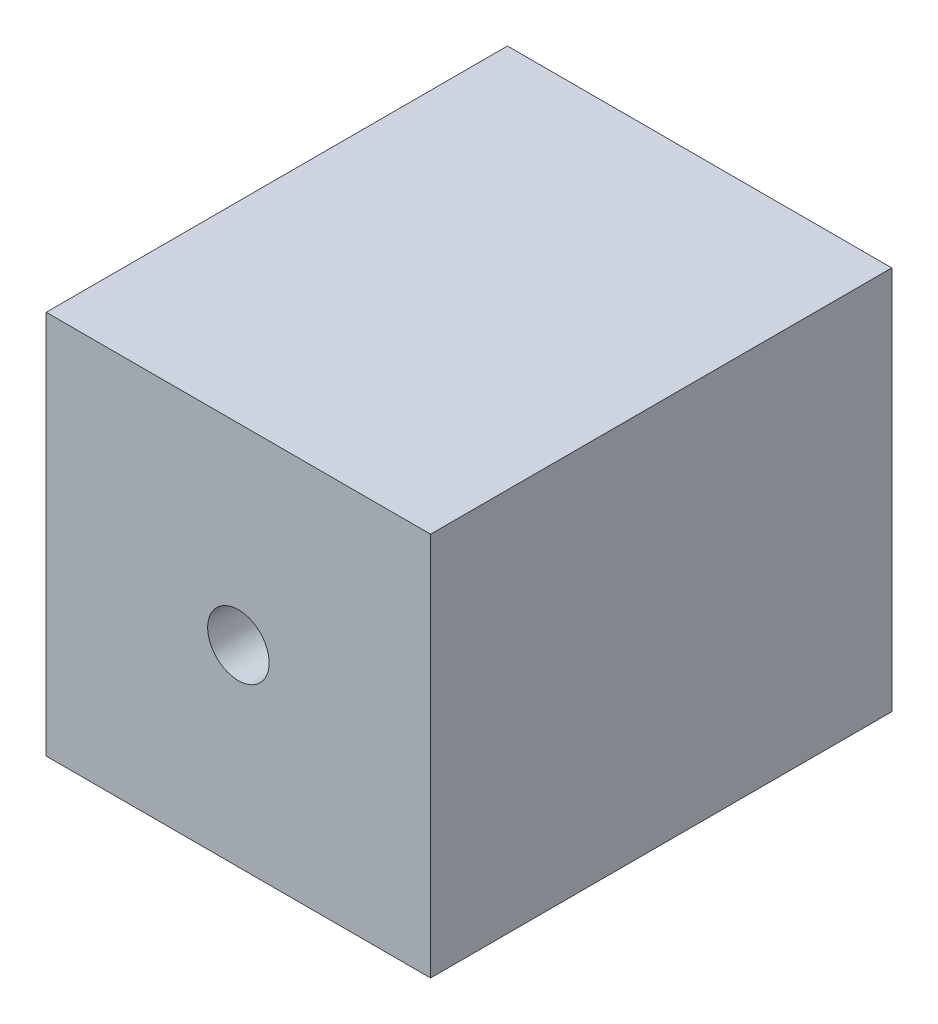
from build123d import *

# Parameters (mm, degrees)
SKETCH1_W                  = 10
SKETCH1_H                  = 10
BOSS_EXTRUDE1_DEPTH        = 12
F_10_32_TAPPED_HOLE1_D     = 4.0386
F_10_32_TAPPED_HOLE1_DEPTH = 5
F_10_32_TAPPED_HOLE1_TIP   = 1.213317848
M2X0_4_TAPPED_HOLE1_D      = 1.6
M2X0_4_TAPPED_HOLE1_DEPTH  = 7
M2X0_4_TAPPED_HOLE1_TIP    = 0.480688495


with BuildPart() as part:
    # Sketch1 → Boss-Extrude1 (new body)
    with BuildSketch(Plane.XY):
        Rectangle(SKETCH1_W, SKETCH1_H)
    extrude(amount=BOSS_EXTRUDE1_DEPTH)

    # #10-32 Tapped Hole1
    with Locations(Plane(origin=(0, 0, 0), x_dir=(1, 0, 0), z_dir=(0, 0, -1))):
        with Locations((0, 0)):
            Hole(F_10_32_TAPPED_HOLE1_D / 2, depth=F_10_32_TAPPED_HOLE1_DEPTH)
            with Locations((0, 0, -(F_10_32_TAPPED_HOLE1_DEPTH + F_10_32_TAPPED_HOLE1_TIP / 2))):  # 118° drill point
                Cone(0, F_10_32_TAPPED_HOLE1_D / 2, F_10_32_TAPPED_HOLE1_TIP, mode=Mode.SUBTRACT)

    # M2x0.4 Tapped Hole1
    with Locations(Plane.XY.offset(12)):
        with Locations((0, 0)):
            Hole(M2X0_4_TAPPED_HOLE1_D / 2, depth=M2X0_4_TAPPED_HOLE1_DEPTH)
            with Locations((0, 0, -(M2X0_4_TAPPED_HOLE1_DEPTH + M2X0_4_TAPPED_HOLE1_TIP / 2))):  # 118° drill point
                Cone(0, M2X0_4_TAPPED_HOLE1_D / 2, M2X0_4_TAPPED_HOLE1_TIP, mode=Mode.SUBTRACT)


solid = part.part
